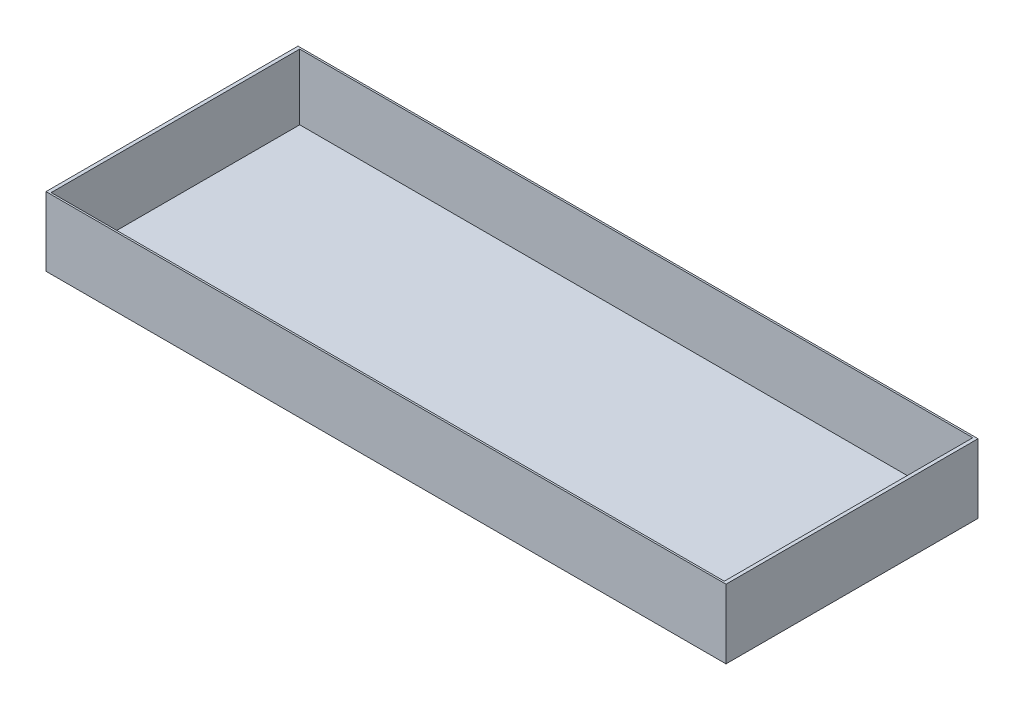
from build123d import *

# Parameters (mm, degrees)
SKETCH1_W           = 197
SKETCH1_H           = 73
BOSS_EXTRUDE1_DEPTH = 20
SKETCH2_W           = 195
SKETCH2_H           = 72
CUT_EXTRUDE1_DEPTH  = 19


with BuildPart() as part:
    # Sketch1 → Boss-Extrude1 (new body)
    with BuildSketch(Plane(origin=(0, 0, 0), x_dir=(1, 0, 0), z_dir=(0, 1, 0))):
        Rectangle(SKETCH1_W, SKETCH1_H)
    extrude(amount=BOSS_EXTRUDE1_DEPTH)

    # Sketch2 → Cut-Extrude1 (cut)
    with BuildSketch(Plane(origin=(0, 20, 0), x_dir=(1, 0, 0), z_dir=(0, 1, 0))):
        Rectangle(SKETCH2_W, SKETCH2_H)
    extrude(amount=-CUT_EXTRUDE1_DEPTH, mode=Mode.SUBTRACT)


solid = part.part
